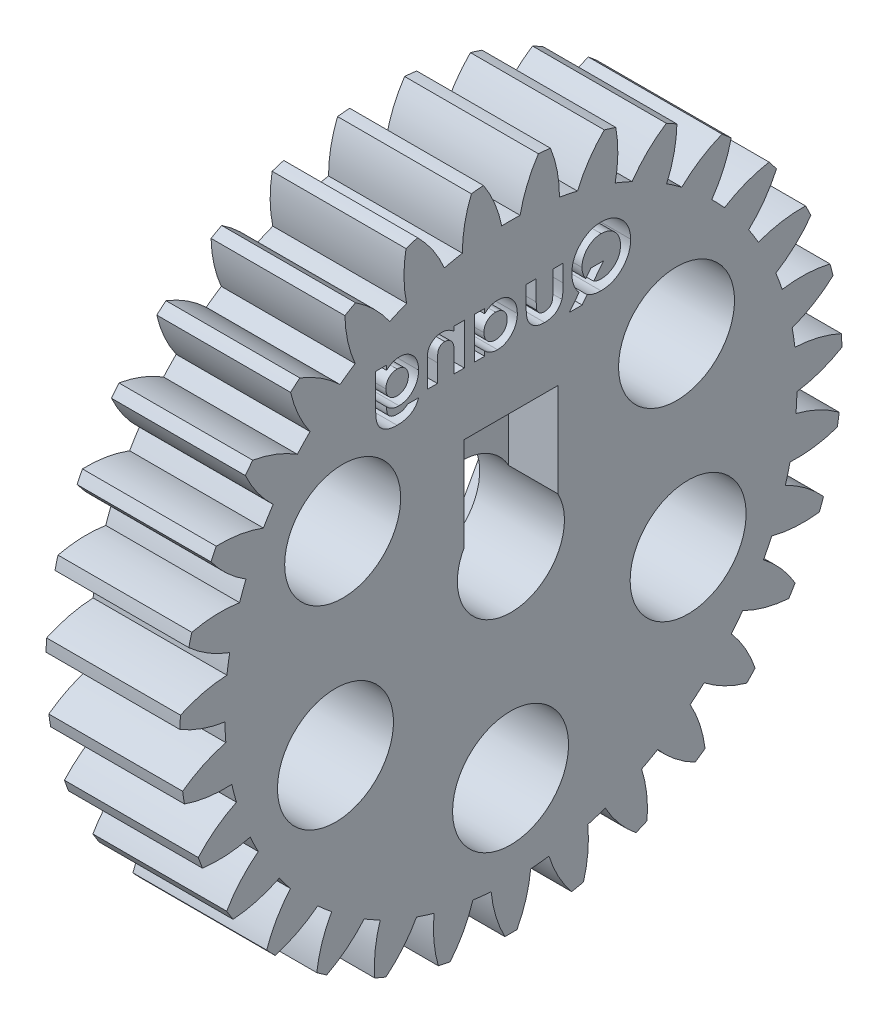
from build123d import *

# Parameters (mm, degrees)
BASPROSKE_W        = 15
BASPROSKE_H        = 37.125
TOOTHCUT_DEPTH     = 55.603399619
TEETHCUTS_COUNT    = 31
BORSKE_R           = 6
BORE_DEPTH         = 50.0000508
CUT_EXTRUDE1_DEPTH = 5.5
CUT_EXTRUDE5_DEPTH = 5.5
SKETCH10_R         = 6.5
CUT_EXTRUDE6_DEPTH = 55.590168897
CUT_EXTRUDE7_DEPTH = 55.590168897


with BuildPart() as part:
    # BasProSke → Base-Revolve (revolve)
    with BuildSketch(Plane(origin=(0, 0, 0), x_dir=(1, 0, 0), z_dir=(0, 1, 0)), mode=Mode.PRIVATE) as base_revolve_sk:
        with Locations((7.5, 18.5625)):
            Rectangle(BASPROSKE_W, BASPROSKE_H)
    revolve(base_revolve_sk.sketch.rotate(Axis((-10, 0, 0), (1, 0, 0)), 180), axis=Axis((-10, 0, 0), (1, 0, 0)))

    # TooCutSke → ToothCut (cut, through all)
    with BuildSketch(Plane(origin=(0, 0, 0), x_dir=(0, 0, -1), z_dir=(1, 0, 0))):
        with BuildLine():
            ThreePointArc((1.030914544, 32.044921555), (0, 32.0615), (-1.030914544, 32.044921555))
            ThreePointArc((-1.030914544, 32.044921555), (-1.820854389, 34.633687107), (-3.095833874, 37.021183568))
            ThreePointArc((-3.095833874, 37.021183568), (0, 37.1504), (3.095833874, 37.021183568))
            ThreePointArc((3.095833874, 37.021183568), (1.820854389, 34.633687107), (1.030914544, 32.044921555))
        make_face()
    toothcut = extrude(amount=TOOTHCUT_DEPTH, mode=Mode.SUBTRACT)

    # TeethCuts: ToothCut ×31 about axis
    teethcuts_axis = Axis((0, 0, 0), (1, 0, 0))
    for i in range(1, TEETHCUTS_COUNT):
        add(toothcut.rotate(teethcuts_axis, i * 360 / TEETHCUTS_COUNT), mode=Mode.SUBTRACT)

    # BorSke → Bore (cut, symmetric)
    with BuildSketch(Plane(origin=(0, 0, 0), x_dir=(0, 0, -1), z_dir=(1, 0, 0))):
        with Locations(Location((0, 0, 0), (0, 0, 180))):
            Circle(BORSKE_R)
    extrude(amount=BORE_DEPTH, both=True, mode=Mode.SUBTRACT)

    # Sketch2 → Cut-Extrude1 (cut)
    with BuildSketch(Plane(origin=(15, 0, 0), x_dir=(0, 0, -1), z_dir=(1, 0, 0))):
        with BuildLine():
            Line((-5.25, 2.90473751), (-5.25, 13.40473751))
            Line((-5.25, 13.40473751), (5.25, 13.40473751))
            Line((5.25, 13.40473751), (5.25, 2.90473751))
            ThreePointArc((5.25, 2.90473751), (0, -6), (-5.25, 2.90473751))
        make_face()
    extrude(amount=-CUT_EXTRUDE1_DEPTH, mode=Mode.SUBTRACT)

    # Sketch8 → Cut-Extrude5 (cut)
    with BuildSketch(Plane.ZY):
        Polygon((13.854005973, -0.294685119), (7.150361146, 11.832191891), (-6.703644827, 12.090103679), (-13.854005973, 0.221138455), (-7.150361146, -11.905738556), (6.703644827, -12.163650343), align=None)
    extrude(amount=-CUT_EXTRUDE5_DEPTH, mode=Mode.SUBTRACT)

    # Sketch10 → Cut-Extrude6 (cut, through all)
    with BuildSketch(Plane.ZY):
        with Locations((-19.863387595, -9.577864097)):
            Circle(SKETCH10_R)
        with Locations((0.040469936, -22.041338682)):
            Circle(SKETCH10_R)
        with Locations((19.66580652, -10.026222395)):
            Circle(SKETCH10_R)
        with Locations((18.858194519, 11.322709237)):
            Circle(SKETCH10_R)
        with Locations((-18.562453348, 11.784144122)):
            Circle(SKETCH10_R)
    extrude(amount=-CUT_EXTRUDE6_DEPTH, mode=Mode.SUBTRACT)

    # Sketch1 → Cut-Extrude7 (cut, through all)
    with BuildSketch(Plane.ZY):
        with BuildLine():
            Line((-7.641186471, 21.253862956), (-6.563772609, 19.86098435))
            Line((-6.563772609, 19.86098435), (-7.98209192, 19.86098435))
            Line((-7.98209192, 19.86098435), (-8.540515397, 20.58222834))
            add(Edge.make_bspline(
                [(-8.540515397, 20.58222834), (-8.599008563, 20.550378263), (-8.715718982, 20.486828344), (-8.898736314, 20.407582104), (-9.085141625, 20.338061517), (-9.277635984, 20.283585216), (-9.474371277, 20.240705753), (-9.676366873, 20.20796658), (-9.883478236, 20.190703942), (-10.023256563, 20.187991686), (-10.093670445, 20.186625375)],
                knots=[0, 0, 0, 0, 0.985706899, 1.966764212, 2.949968678, 3.929638882, 4.925906056, 5.930211904, 6.957336097, 8, 8, 8, 8], degree=3))
            add(Edge.make_bspline(
                [(-10.093670445, 20.186625375), (-10.210880259, 20.18925615), (-10.440772545, 20.194416084), (-10.777455868, 20.243961561), (-11.099762177, 20.318761769), (-11.406495093, 20.428048698), (-11.698687954, 20.566928028), (-11.974004928, 20.739035754), (-12.23564842, 20.93960012), (-12.477217009, 21.170589506), (-12.6982485, 21.420909481), (-12.891377178, 21.686855548), (-13.055549237, 21.964278382), (-13.189436194, 22.253613167), (-13.293546912, 22.555358711), (-13.366454823, 22.868690851), (-13.412677272, 23.194042611), (-13.418406665, 23.414894425), (-13.421314676, 23.526989959)],
                knots=[0, 0, 0, 0, 1.070144486, 2.098953612, 3.10240755, 4.088674545, 5.067611437, 6.052256776, 7.0494179, 8.074208254, 9.100739571, 10.09639475, 11.072322686, 12.041159829, 13.004031207, 13.983083054, 14.976293755, 16, 16, 16, 16], degree=3))
            add(Edge.make_bspline(
                [(-13.421314676, 23.526989959), (-13.420345258, 23.60210065), (-13.418418696, 23.75137096), (-13.395247606, 23.972587111), (-13.361816544, 24.189465169), (-13.312731245, 24.400839378), (-13.252205704, 24.608260467), (-13.175195253, 24.810079235), (-13.085947346, 25.008212108), (-12.983560241, 25.201013084), (-12.867262291, 25.385631499), (-12.743678018, 25.563534305), (-12.606210089, 25.729009408), (-12.459724098, 25.885783358), (-12.303738891, 26.033753471), (-12.135797934, 26.169869763), (-11.959092572, 26.297510154), (-11.772349608, 26.413998694), (-11.578810958, 26.519293027), (-11.380257916, 26.610800943), (-11.178201723, 26.689085055), (-10.972566994, 26.752856596), (-10.762728229, 26.800646937), (-10.550531843, 26.837034088), (-10.334053702, 26.857274846), (-10.188687803, 26.860591752), (-10.115295045, 26.862266401)],
                knots=[0, 0, 0, 0, 1.035855852, 2.058595393, 3.065553363, 4.06176554, 5.050183643, 6.044349766, 7.039272903, 8.046842428, 9.053256483, 10.04817962, 11.033146707, 12.018200652, 13.007259073, 13.996749908, 14.99846043, 16.012935138, 17.03119782, 18.036301871, 19.027088812, 20.018894167, 21.003704893, 21.994284571, 22.987348552, 24, 24, 24, 24], degree=3))
            add(Edge.make_bspline(
                [(-10.115295045, 26.862266401), (-10.004460187, 26.859448074), (-9.786059909, 26.853894556), (-9.464794519, 26.806406983), (-9.154984646, 26.730760422), (-8.857907783, 26.621465962), (-8.571748198, 26.483660245), (-8.299357848, 26.31314767), (-8.037854341, 26.113444463), (-7.792887064, 25.884454725), (-7.56650124, 25.635945717), (-7.36914622, 25.369323247), (-7.202073321, 25.08967801), (-7.062741889, 24.796898515), (-6.957771037, 24.489273684), (-6.882834444, 24.168845952), (-6.835401763, 23.835389886), (-6.8298867, 23.608136671), (-6.827083907, 23.492645007)],
                knots=[0, 0, 0, 0, 1.015551519, 2.00114601, 2.970254478, 3.93428303, 4.897362978, 5.876714212, 6.874912676, 7.909046156, 8.946527051, 9.952474942, 10.9443724, 11.928494229, 12.919233427, 13.917651329, 14.941735923, 16, 16, 16, 16], degree=3))
            add(Edge.make_bspline(
                [(-6.827083907, 23.492645007), (-6.829414032, 23.386095041), (-6.83399693, 23.176532258), (-6.873699855, 22.86759324), (-6.93636794, 22.569817408), (-7.026374597, 22.282993142), (-7.140437741, 22.007433074), (-7.282560761, 21.74395756), (-7.446446536, 21.489438608), (-7.57594954, 21.332779653), (-7.641186471, 21.253862956)],
                knots=[0, 0, 0, 0, 1.049646143, 2.064447078, 3.064298101, 4.044929938, 5.022708814, 5.998521441, 6.991758374, 8, 8, 8, 8], degree=3))
        make_face()
        with BuildLine():
            add(Edge.make_bspline(
                [(-8.389143202, 22.223153821), (-8.355216616, 22.271794044), (-8.288145085, 22.367953859), (-8.203277946, 22.520476402), (-8.130376114, 22.675970785), (-8.070089153, 22.835252945), (-8.024228931, 22.999235703), (-7.99163252, 23.166848526), (-7.97004659, 23.338168176), (-7.967906139, 23.453570571), (-7.966827496, 23.511725536)],
                knots=[0, 0, 0, 0, 1.031533623, 2.039301536, 3.033003023, 4.018477747, 4.999688364, 5.992485227, 6.988348989, 8, 8, 8, 8], degree=3))
            add(Edge.make_bspline(
                [(-7.966827496, 23.511725536), (-7.968835024, 23.587291547), (-7.972786534, 23.736031717), (-8.00246554, 23.954681956), (-8.052185579, 24.16422786), (-8.121512714, 24.365182316), (-8.208819263, 24.558061171), (-8.318494734, 24.741258373), (-8.447349008, 24.915725421), (-8.594138221, 25.079782123), (-8.753953138, 25.229930322), (-8.923920183, 25.362166764), (-9.102873443, 25.473726777), (-9.290917602, 25.563804203), (-9.486012833, 25.636355177), (-9.690252803, 25.685051764), (-9.901857336, 25.716980549), (-10.046062508, 25.720659301), (-10.11911115, 25.722522811)],
                knots=[0, 0, 0, 0, 1.056263418, 2.079093448, 3.078410197, 4.062632158, 5.04680056, 6.032966551, 7.041959893, 8.074807684, 9.106532056, 10.103754224, 11.080880922, 12.048629763, 13.014470275, 13.984975, 14.979267944, 16, 16, 16, 16], degree=3))
            add(Edge.make_bspline(
                [(-10.11911115, 25.722522811), (-10.194263213, 25.720556592), (-10.342178552, 25.716686652), (-10.559331029, 25.686435276), (-10.767626119, 25.638984866), (-10.965968935, 25.569315654), (-11.154960023, 25.481530925), (-11.334590713, 25.373817356), (-11.503960766, 25.245571809), (-11.663472867, 25.100550705), (-11.807597629, 24.939629641), (-11.934868315, 24.767068306), (-12.041390578, 24.583282804), (-12.130599072, 24.389946767), (-12.197754431, 24.184895177), (-12.24558688, 23.969731807), (-12.275815279, 23.744086586), (-12.2796256, 23.590264507), (-12.281571086, 23.511725536)],
                knots=[0, 0, 0, 0, 1.042613217, 2.052085894, 3.036973397, 4.002832266, 4.963730975, 5.924467509, 6.903642813, 7.907474205, 8.911719447, 9.896835452, 10.877830278, 11.85475743, 12.846581833, 13.865885605, 14.910357018, 16, 16, 16, 16], degree=3))
            add(Edge.make_bspline(
                [(-12.281571086, 23.511725536), (-12.278992235, 23.42468629), (-12.273938115, 23.25410379), (-12.238360872, 23.005269419), (-12.177534183, 22.770244456), (-12.08955614, 22.550297755), (-11.98083894, 22.342332537), (-11.84387385, 22.150778083), (-11.684608625, 21.97184692), (-11.561667409, 21.867693093), (-11.499269404, 21.814830504)],
                knots=[0, 0, 0, 0, 1.078047314, 2.112794111, 3.106520711, 4.077995885, 5.041371964, 6.006121678, 6.988020189, 8, 8, 8, 8], degree=3))
            add(Edge.make_bspline(
                [(-11.499269404, 21.814830504), (-11.448215961, 21.775698756), (-11.346972677, 21.698097198), (-11.184789839, 21.599869275), (-11.018561967, 21.51453824), (-10.846717288, 21.446317006), (-10.669849446, 21.392060924), (-10.487996051, 21.354477525), (-10.300801881, 21.330554081), (-10.174306058, 21.327776465), (-10.110206904, 21.326368965)],
                knots=[0, 0, 0, 0, 1.027457745, 2.037535419, 3.025615023, 4.011018129, 4.9886297, 5.978868484, 6.975833209, 8, 8, 8, 8], degree=3))
            add(Edge.make_bspline(
                [(-10.110206904, 21.326368965), (-10.036663248, 21.328710676), (-9.890692627, 21.333358542), (-9.675836839, 21.373845591), (-9.46649759, 21.434394899), (-9.335258453, 21.496287577), (-9.269391599, 21.527350536)],
                knots=[0, 0, 0, 0, 1.010952568, 2.006554787, 2.999521277, 4, 4, 4, 4], degree=3))
            Line((-9.269391599, 21.527350536), (-10.372246166, 22.954574093))
            Line((-10.372246166, 22.954574093), (-8.953926855, 22.954574093))
            Line((-8.953926855, 22.954574093), (-8.389143202, 22.223153821))
        make_face(mode=Mode.SUBTRACT)
        with BuildLine():
            Line((-5.85016083, 24.989830504), (-4.71041724, 24.989830504))
            Line((-4.71041724, 24.989830504), (-4.71041724, 22.76249677))
            add(Edge.make_bspline(
                [(-4.71041724, 22.76249677), (-4.71031603, 22.71033799), (-4.710121784, 22.610232554), (-4.704716541, 22.46646155), (-4.697131918, 22.33498955), (-4.68766682, 22.215661525), (-4.673539556, 22.108764498), (-4.657230225, 22.01450254), (-4.638740705, 21.93219648), (-4.608674411, 21.840455403), (-4.561635151, 21.740062438), (-4.490597542, 21.633483517), (-4.404550277, 21.541323914), (-4.304655914, 21.462765759), (-4.189894285, 21.400860208), (-4.061846505, 21.358907761), (-3.922123676, 21.330711354), (-3.824806935, 21.327854576), (-3.774199291, 21.326368965)],
                knots=[0, 0, 0, 0, 1.267339619, 2.432334223, 3.495366327, 4.467371443, 5.340232306, 6.114347373, 6.791623365, 7.387877112, 8.457231658, 9.474542289, 10.487879852, 11.508108106, 12.54995813, 13.638205937, 14.771795776, 16, 16, 16, 16], degree=3))
            add(Edge.make_bspline(
                [(-3.774199291, 21.326368965), (-3.723636557, 21.32806458), (-3.626068139, 21.331336524), (-3.48541568, 21.356852016), (-3.357066298, 21.40057366), (-3.239701762, 21.459876911), (-3.136783159, 21.539244211), (-3.047176141, 21.63381598), (-2.971729134, 21.745117777), (-2.935473368, 21.828145728), (-2.916847529, 21.870800055)],
                knots=[0, 0, 0, 0, 1.116871431, 2.155171802, 3.144773418, 4.104381479, 5.046960687, 6.001340237, 6.973219418, 8, 8, 8, 8], degree=3))
            add(Edge.make_bspline(
                [(-2.916847529, 21.870800055), (-2.910012471, 21.88974749), (-2.89492487, 21.931571767), (-2.881496607, 22.0037244), (-2.867043797, 22.088816748), (-2.855611111, 22.188582922), (-2.849142093, 22.302405061), (-2.842211204, 22.430426618), (-2.838679098, 22.572520094), (-2.83822105, 22.67218091), (-2.837981343, 22.724335712)],
                knots=[0, 0, 0, 0, 0.56094539, 1.238222264, 2.041156151, 2.969685991, 4.036367568, 5.220421584, 6.545382566, 8, 8, 8, 8], degree=3))
            Line((-2.837981343, 22.724335712), (-2.837981343, 24.989830504))
            Line((-2.837981343, 24.989830504), (-1.698237753, 24.989830504))
            Line((-1.698237753, 24.989830504), (-1.698237753, 23.039800456))
            add(Edge.make_bspline(
                [(-1.698237753, 23.039800456), (-1.698435098, 22.94311383), (-1.698813469, 22.757736306), (-1.709657351, 22.491818272), (-1.724623137, 22.250045703), (-1.743896189, 22.031752923), (-1.771666277, 21.83684934), (-1.805755539, 21.665792008), (-1.843469146, 21.517450556), (-1.87805393, 21.429557221), (-1.894131182, 21.388698693)],
                knots=[0, 0, 0, 0, 1.388070971, 2.661352173, 3.82033814, 4.865898334, 5.806910977, 6.645039373, 7.370126333, 8, 8, 8, 8], degree=3))
            add(Edge.make_bspline(
                [(-1.894131182, 21.388698693), (-1.91473808, 21.344722292), (-1.955414324, 21.257916656), (-2.02599517, 21.134498266), (-2.102085275, 21.01756912), (-2.187305036, 20.909881613), (-2.279914853, 20.810341277), (-2.377296938, 20.716685317), (-2.483836874, 20.632727545), (-2.596771687, 20.556307491), (-2.717677224, 20.488470053), (-2.845725373, 20.428354593), (-2.982299896, 20.379430917), (-3.126216531, 20.337961201), (-3.278138638, 20.307035101), (-3.43776019, 20.28361094), (-3.605256251, 20.271505244), (-3.719485463, 20.269211119), (-3.778015397, 20.268035632)],
                knots=[0, 0, 0, 0, 0.997311338, 1.968606903, 2.91805772, 3.860812155, 4.785445165, 5.709667791, 6.633356648, 7.568312411, 8.508286151, 9.478643871, 10.470653671, 11.485274776, 12.552984541, 13.653035246, 14.797438149, 16, 16, 16, 16], degree=3))
            add(Edge.make_bspline(
                [(-3.778015397, 20.268035632), (-3.841244173, 20.268789152), (-3.964961447, 20.270263535), (-4.145710655, 20.288318955), (-4.31796708, 20.31168032), (-4.479807491, 20.351398923), (-4.633492063, 20.397414911), (-4.777256411, 20.456143552), (-4.911687991, 20.525191794), (-5.037051317, 20.60415028), (-5.152374117, 20.693742581), (-5.26022072, 20.790095982), (-5.357109376, 20.897044079), (-5.446203105, 21.011284273), (-5.526507571, 21.133867972), (-5.598062631, 21.264359306), (-5.660928898, 21.403351815), (-5.694471169, 21.500765718), (-5.711508987, 21.55024717)],
                knots=[0, 0, 0, 0, 1.211240017, 2.369985978, 3.478996442, 4.539426614, 5.559871561, 6.551301256, 7.510778031, 8.453136967, 9.386094087, 10.30661716, 11.221130616, 12.147659962, 13.080758632, 14.026335491, 14.997475882, 16, 16, 16, 16], degree=3))
            add(Edge.make_bspline(
                [(-5.711508987, 21.55024717), (-5.723132742, 21.58867636), (-5.748173019, 21.671461794), (-5.775208847, 21.809041523), (-5.796833085, 21.967609864), (-5.81786846, 22.14732279), (-5.832543122, 22.348481592), (-5.842134656, 22.570766802), (-5.848615359, 22.814613099), (-5.849630496, 22.984250427), (-5.85016083, 23.072873372)],
                knots=[0, 0, 0, 0, 0.627914866, 1.352675004, 2.190563461, 3.132055958, 4.183353232, 5.345633452, 6.613289997, 8, 8, 8, 8], degree=3))
            Line((-5.85016083, 23.072873372), (-5.85016083, 24.989830504))
        make_face()
        with BuildLine():
            Line((2.942146863, 24.989830504), (4.081890452, 24.989830504))
            Line((4.081890452, 24.989830504), (4.081890452, 20.349445888))
            Line((4.081890452, 20.349445888), (2.942146863, 20.349445888))
            Line((2.942146863, 20.349445888), (2.942146863, 20.85571592))
            add(Edge.make_bspline(
                [(2.942146863, 20.85571592), (2.885672988, 20.806436136), (2.776068349, 20.710793806), (2.603366904, 20.586695452), (2.430160806, 20.484330348), (2.255617794, 20.402802125), (2.077055215, 20.342601924), (1.893187491, 20.299015572), (1.701366731, 20.273311634), (1.570969621, 20.269812618), (1.504747023, 20.268035632)],
                knots=[0, 0, 0, 0, 1.129196829, 2.191548051, 3.199897424, 4.157751732, 5.089409408, 6.034969131, 7.002052659, 8, 8, 8, 8], degree=3))
            add(Edge.make_bspline(
                [(1.504747023, 20.268035632), (1.430409213, 20.269708), (1.283513487, 20.273012694), (1.067960317, 20.307799935), (0.859822302, 20.36104956), (0.659268392, 20.436404435), (0.466663477, 20.53404958), (0.280533544, 20.651437297), (0.104069428, 20.792688597), (-0.064197874, 20.951691896), (-0.218262406, 21.126596656), (-0.352947074, 21.314975224), (-0.46647624, 21.514155864), (-0.559484611, 21.723478202), (-0.632647705, 21.942788606), (-0.684802522, 22.172782664), (-0.715573924, 22.413542516), (-0.719382557, 22.577538698), (-0.721314676, 22.660733949)],
                knots=[0, 0, 0, 0, 0.980476535, 1.937477201, 2.874147792, 3.812856188, 4.758993464, 5.720109578, 6.712210464, 7.737600662, 8.772720504, 9.783789959, 10.789002326, 11.793715968, 12.802552247, 13.835794126, 14.902098527, 16, 16, 16, 16], degree=3))
            add(Edge.make_bspline(
                [(-0.721314676, 22.660733949), (-0.71928691, 22.746882741), (-0.715309221, 22.915873194), (-0.686212662, 23.16385865), (-0.635020298, 23.399555391), (-0.565215829, 23.623289891), (-0.475424501, 23.835100804), (-0.366064663, 24.035335142), (-0.235648576, 24.223469527), (-0.085367156, 24.396301777), (0.076899866, 24.554710883), (0.250496894, 24.692618571), (0.43270925, 24.80977757), (0.623730565, 24.905424778), (0.823533562, 24.9793361), (1.031329421, 25.033371312), (1.248040608, 25.065794337), (1.395666026, 25.069410209), (1.470402071, 25.07124076)],
                knots=[0, 0, 0, 0, 1.136281865, 2.228943489, 3.287578264, 4.313574083, 5.316051562, 6.317280042, 7.318008486, 8.329309503, 9.333984563, 10.305318864, 11.248632312, 12.186624717, 13.117503092, 14.05354244, 15.014596925, 16, 16, 16, 16], degree=3))
            add(Edge.make_bspline(
                [(1.470402071, 25.07124076), (1.539631865, 25.069802497), (1.676612673, 25.066956692), (1.877954724, 25.036056696), (2.073227475, 24.989322647), (2.261365702, 24.922735039), (2.443912577, 24.838654637), (2.61772818, 24.733295627), (2.786614883, 24.6110862), (2.889662326, 24.515638048), (2.942146863, 24.467024013)],
                knots=[0, 0, 0, 0, 1.017011718, 2.012299608, 2.98747302, 3.965332399, 4.941441765, 5.936729654, 6.94912688, 8, 8, 8, 8], degree=3))
            Line((2.942146863, 24.467024013), (2.942146863, 24.989830504))
        make_face()
        with BuildLine():
            add(Edge.make_bspline(
                [(1.709544699, 24.012907427), (1.664129277, 24.011513925), (1.575118014, 24.008782752), (1.444214772, 23.992354557), (1.319110541, 23.963407346), (1.200697556, 23.920644057), (1.087211028, 23.868552141), (0.980374268, 23.803307874), (0.879305519, 23.726190536), (0.784599178, 23.639067138), (0.698260394, 23.543302594), (0.623831323, 23.438802728), (0.560578638, 23.328383217), (0.507083305, 23.211712069), (0.468792783, 23.087408701), (0.438466706, 22.957091325), (0.422729435, 22.819695312), (0.419876764, 22.726064181), (0.418428914, 22.678542443)],
                knots=[0, 0, 0, 0, 1.04836806, 2.054732945, 3.03993516, 4.00574415, 4.955904794, 5.917688631, 6.888591924, 7.88601754, 8.884115178, 9.859153345, 10.841239365, 11.818093293, 12.814750328, 13.83810466, 14.90274714, 16, 16, 16, 16], degree=3))
            add(Edge.make_bspline(
                [(0.418428914, 22.678542443), (0.419854648, 22.630589654), (0.422664041, 22.536099241), (0.438721163, 22.397544243), (0.467955982, 22.265323236), (0.510608482, 22.140505135), (0.562697077, 22.021405732), (0.626100612, 21.908574681), (0.703980749, 21.804006977), (0.790395218, 21.705228197), (0.887044445, 21.617022579), (0.988685082, 21.53870409), (1.096705459, 21.473175059), (1.209933631, 21.420214083), (1.327988468, 21.377055338), (1.45235002, 21.348471934), (1.581800007, 21.330199105), (1.670049482, 21.327654494), (1.71463284, 21.326368965)],
                knots=[0, 0, 0, 0, 1.099136573, 2.165835871, 3.191374663, 4.196217796, 5.183857741, 6.167377911, 7.154730987, 8.166690795, 9.170734848, 10.148332609, 11.103258353, 12.059567475, 13.009337315, 13.978056681, 14.978520572, 16, 16, 16, 16], degree=3))
            add(Edge.make_bspline(
                [(1.71463284, 21.326368965), (1.760894178, 21.327770279), (1.851591548, 21.330517617), (1.984630411, 21.346795887), (2.11141524, 21.375849236), (2.231418542, 21.418857353), (2.346473254, 21.470575353), (2.455541111, 21.534544697), (2.557438561, 21.611485072), (2.652681668, 21.699396068), (2.739953616, 21.795942587), (2.815411982, 21.901812803), (2.881138979, 22.013620695), (2.932830239, 22.134009811), (2.973880348, 22.260873902), (3.003332854, 22.395000315), (3.01935331, 22.536533652), (3.022138132, 22.63313567), (3.023557119, 22.682358548)],
                knots=[0, 0, 0, 0, 1.050008698, 2.058587853, 3.036635738, 3.995319155, 4.947022481, 5.895997462, 6.858296291, 7.838991643, 8.833936038, 9.806048392, 10.784806122, 11.771666913, 12.772873988, 13.80724452, 14.882696879, 16, 16, 16, 16], degree=3))
            add(Edge.make_bspline(
                [(3.023557119, 22.682358548), (3.022155765, 22.730734817), (3.019418513, 22.825227721), (3.003263762, 22.963805909), (2.97360216, 23.095298691), (2.93339693, 23.219947768), (2.880786067, 23.33746813), (2.815009339, 23.446556757), (2.740378708, 23.550993161), (2.652140533, 23.644931424), (2.557413379, 23.732205877), (2.454017362, 23.806819518), (2.345210018, 23.871123625), (2.230322831, 23.923919777), (2.108292, 23.962621357), (1.981290504, 23.992586575), (1.847336857, 24.008772892), (1.756224956, 24.011506758), (1.709544699, 24.012907427)],
                knots=[0, 0, 0, 0, 1.106611376, 2.161533483, 3.185006901, 4.184773755, 5.152708835, 6.122342771, 7.094156588, 8.082475533, 9.064254463, 10.03606828, 10.992420271, 11.951521816, 12.920622147, 13.915721683, 14.932141191, 16, 16, 16, 16], degree=3))
        make_face(mode=Mode.SUBTRACT)
        with BuildLine():
            Line((5.221634042, 24.989830504), (6.361377632, 24.989830504))
            Line((6.361377632, 24.989830504), (6.361377632, 24.498824895))
            add(Edge.make_bspline(
                [(6.361377632, 24.498824895), (6.426399439, 24.549400195), (6.550668751, 24.646059426), (6.739579563, 24.769300438), (6.917887979, 24.870168257), (7.089568688, 24.946893482), (7.257851864, 25.002093983), (7.425462975, 25.041752249), (7.59489809, 25.067146528), (7.708799616, 25.069876748), (7.765704555, 25.07124076)],
                knots=[0, 0, 0, 0, 1.276643801, 2.439914479, 3.493451431, 4.44993799, 5.350072675, 6.235028322, 7.118224225, 8, 8, 8, 8], degree=3))
            add(Edge.make_bspline(
                [(7.765704555, 25.07124076), (7.823426958, 25.069681977), (7.936740883, 25.066621955), (8.103589393, 25.045219578), (8.262996941, 25.006239071), (8.416755934, 24.9544835), (8.563301367, 24.886169114), (8.704428512, 24.805056865), (8.837106008, 24.706256658), (8.918814683, 24.631015164), (8.960145661, 24.592955504)],
                knots=[0, 0, 0, 0, 1.048836932, 2.058954983, 3.049370783, 4.026390553, 5.001981509, 5.982488534, 6.97947532, 8, 8, 8, 8], degree=3))
            add(Edge.make_bspline(
                [(8.960145661, 24.592955504), (8.993294626, 24.557685328), (9.059835167, 24.48688684), (9.143568077, 24.365732494), (9.215420333, 24.233652082), (9.274293272, 24.089122012), (9.317798003, 23.931348187), (9.351266785, 23.762236287), (9.370046703, 23.580839411), (9.372365172, 23.456221469), (9.373557119, 23.392154222)],
                knots=[0, 0, 0, 0, 0.889584746, 1.785680191, 2.700364693, 3.65222533, 4.649950538, 5.707241244, 6.821271309, 8, 8, 8, 8], degree=3))
            Line((9.373557119, 23.392154222), (9.373557119, 20.349445888))
            Line((9.373557119, 20.349445888), (8.233813529, 20.349445888))
            Line((8.233813529, 20.349445888), (8.233813529, 22.364349734))
            add(Edge.make_bspline(
                [(8.233813529, 22.364349734), (8.233572499, 22.430072388), (8.233110608, 22.556017654), (8.229564312, 22.736264258), (8.222639875, 22.899050349), (8.216328432, 23.044672313), (8.20393656, 23.172613095), (8.192761369, 23.283682656), (8.175614122, 23.376873367), (8.153302773, 23.477113959), (8.114341661, 23.584439844), (8.053856434, 23.697525394), (7.977122442, 23.79359409), (7.887273808, 23.873319421), (7.784409761, 23.936389471), (7.669773265, 23.980763179), (7.543978908, 24.008417964), (7.456326878, 24.011372864), (7.410806718, 24.012907427)],
                knots=[0, 0, 0, 0, 1.49886392, 2.872294502, 4.110984203, 5.214877267, 6.195405875, 7.042225351, 7.75923308, 8.355011229, 9.382752534, 10.352059385, 11.267231453, 12.171456522, 13.078624015, 14.003401117, 14.963110155, 16, 16, 16, 16], degree=3))
            add(Edge.make_bspline(
                [(7.410806718, 24.012907427), (7.351605836, 24.009905334), (7.235797402, 24.004032657), (7.068303669, 23.959747317), (6.914463467, 23.88443099), (6.775533795, 23.780208337), (6.652837843, 23.651532558), (6.551782202, 23.49807193), (6.468895816, 23.323530217), (6.433253438, 23.196086416), (6.414803113, 23.130114959)],
                knots=[0, 0, 0, 0, 0.984188326, 1.925263693, 2.85911992, 3.81709677, 4.80007086, 5.801799564, 6.862098548, 8, 8, 8, 8], degree=3))
            add(Edge.make_bspline(
                [(6.414803113, 23.130114959), (6.410217474, 23.10939618), (6.399990577, 23.063189139), (6.391580248, 22.985127394), (6.37988087, 22.892514691), (6.375497401, 22.783675001), (6.36787503, 22.659123418), (6.365055913, 22.518695162), (6.362231752, 22.362665589), (6.361671771, 22.253684861), (6.361377632, 22.196441081)],
                knots=[0, 0, 0, 0, 0.543362196, 1.211806945, 2.009705693, 2.934833164, 4.000995085, 5.207458376, 6.533175157, 8, 8, 8, 8], degree=3))
            Line((6.361377632, 22.196441081), (6.361377632, 20.349445888))
            Line((6.361377632, 20.349445888), (5.221634042, 20.349445888))
            Line((5.221634042, 20.349445888), (5.221634042, 24.989830504))
        make_face()
        with BuildLine():
            Line((13.932531478, 24.989830504), (15.153685324, 24.989830504))
            Line((15.153685324, 24.989830504), (15.153685324, 21.031256786))
            add(Edge.make_bspline(
                [(15.153685324, 21.031256786), (15.152217815, 20.936659481), (15.149383998, 20.753988371), (15.127766832, 20.48925075), (15.091717421, 20.243824413), (15.039843591, 20.01736178), (14.972846046, 19.810695208), (14.890905506, 19.623137633), (14.795687993, 19.453683236), (14.717398003, 19.354666964), (14.679216173, 19.306376978)],
                knots=[0, 0, 0, 0, 1.243822755, 2.401870584, 3.490053692, 4.503076575, 5.453444971, 6.342269266, 7.191528908, 8, 8, 8, 8], degree=3))
            add(Edge.make_bspline(
                [(14.679216173, 19.306376978), (14.624386538, 19.24623512), (14.515004857, 19.12625589), (14.322158823, 18.974846347), (14.110888888, 18.84543933), (13.879039008, 18.739384077), (13.626885341, 18.658603808), (13.355075645, 18.600427618), (13.063437601, 18.564192746), (12.862011007, 18.560380434), (12.758442936, 18.558420247)],
                knots=[0, 0, 0, 0, 0.916003385, 1.827369254, 2.751972866, 3.703651841, 4.69362366, 5.730423306, 6.83304546, 8, 8, 8, 8], degree=3))
            add(Edge.make_bspline(
                [(12.758442936, 18.558420247), (12.648965494, 18.56011509), (12.438412183, 18.563374709), (12.135851415, 18.595261256), (11.860247711, 18.647728369), (11.610306839, 18.721594628), (11.383700231, 18.816903465), (11.176154659, 18.931184259), (10.988068709, 19.067816355), (10.816599373, 19.221413228), (10.665723349, 19.395347943), (10.536890027, 19.588028009), (10.427130734, 19.797681153), (10.372935835, 19.947607133), (10.345392055, 20.023804863)],
                knots=[0, 0, 0, 0, 1.29412125, 2.488928388, 3.592140377, 4.607309753, 5.564519828, 6.493640275, 7.402258018, 8.307438948, 9.210158992, 10.116782752, 11.042881838, 12, 12, 12, 12], degree=3))
            Line((10.345392055, 20.023804863), (11.61233917, 20.023804863))
            add(Edge.make_bspline(
                [(11.61233917, 20.023804863), (11.641616964, 19.991572803), (11.700544615, 19.926699076), (11.80477157, 19.844378711), (11.920070207, 19.773916492), (12.047370751, 19.716219291), (12.187203986, 19.672345743), (12.338618048, 19.639013628), (12.502291152, 19.620229236), (12.615080143, 19.617935746), (12.673216574, 19.616753581)],
                knots=[0, 0, 0, 0, 0.888971165, 1.789239437, 2.70354581, 3.646217955, 4.638595249, 5.694475788, 6.811630907, 8, 8, 8, 8], degree=3))
            add(Edge.make_bspline(
                [(12.673216574, 19.616753581), (12.746685736, 19.61812631), (12.887005397, 19.620748103), (13.085526763, 19.649414559), (13.262810236, 19.692240568), (13.416296641, 19.756692666), (13.548716839, 19.834108504), (13.659187529, 19.924037065), (13.75040419, 20.023090273), (13.810069431, 20.11627514), (13.845524737, 20.200808923), (13.869667686, 20.273802628), (13.888002101, 20.357941121), (13.904691256, 20.451649635), (13.91716667, 20.556135447), (13.925431792, 20.671177204), (13.932598893, 20.796268056), (13.932554446, 20.8832649), (13.932531478, 20.92822193)],
                knots=[0, 0, 0, 0, 1.656375485, 3.163532, 4.516250129, 5.759907703, 6.905105653, 7.965920022, 8.961443813, 9.932912751, 10.442911961, 11.026787936, 11.664959534, 12.383728702, 13.174001396, 14.037595414, 14.985895623, 16, 16, 16, 16], degree=3))
            add(Edge.make_bspline(
                [(13.932531478, 20.92822193), (13.882599658, 20.879249512), (13.785163039, 20.783685063), (13.62698991, 20.661765401), (13.465071703, 20.561062761), (13.2984779, 20.481008572), (13.123895329, 20.422370291), (12.940298602, 20.38025595), (12.745596783, 20.354595011), (12.611813335, 20.351186933), (12.543468978, 20.349445888)],
                knots=[0, 0, 0, 0, 1.082007397, 2.111422008, 3.08419067, 4.02964304, 4.965866572, 5.929243163, 6.942137121, 8, 8, 8, 8], degree=3))
            add(Edge.make_bspline(
                [(12.543468978, 20.349445888), (12.467872165, 20.351192318), (12.319373217, 20.354622925), (12.101258822, 20.38796172), (11.891997456, 20.439833632), (11.691025641, 20.512044185), (11.500394072, 20.607914258), (11.317389992, 20.721972902), (11.145405001, 20.860209248), (10.982066361, 21.01490649), (10.834437141, 21.186859244), (10.704532557, 21.37153627), (10.595019735, 21.567663669), (10.505960667, 21.775059119), (10.435003356, 21.992851984), (10.386169621, 22.222221341), (10.356328414, 22.462779912), (10.352455519, 22.626725063), (10.350480196, 22.710343324)],
                knots=[0, 0, 0, 0, 1.007560175, 1.979205489, 2.935124557, 3.879618859, 4.820364716, 5.775815361, 6.749909327, 7.75781854, 8.772289371, 9.766897274, 10.764314289, 11.762244114, 12.772609037, 13.814079916, 14.885097635, 16, 16, 16, 16], degree=3))
            add(Edge.make_bspline(
                [(10.350480196, 22.710343324), (10.352205445, 22.799491717), (10.35557723, 22.973721142), (10.388630342, 23.228205465), (10.440062584, 23.469895299), (10.51348346, 23.698285082), (10.609942015, 23.912398458), (10.726508321, 24.112914829), (10.862082775, 24.302127177), (10.969401281, 24.414374938), (11.023386846, 24.470840119)],
                knots=[0, 0, 0, 0, 1.104124469, 2.157873671, 3.173961494, 4.162551312, 5.124378318, 6.07778831, 7.033049473, 8, 8, 8, 8], degree=3))
            add(Edge.make_bspline(
                [(11.023386846, 24.470840119), (11.07461837, 24.518986658), (11.175572645, 24.613861819), (11.34083448, 24.735602397), (11.511991435, 24.840019442), (11.691391116, 24.924011182), (11.877764091, 24.990897606), (12.072213705, 25.037689968), (12.273773103, 25.06654106), (12.410656451, 25.069662501), (12.479867215, 25.07124076)],
                knots=[0, 0, 0, 0, 1.042068658, 2.053448347, 3.038272799, 4.011764631, 4.986555969, 5.970496305, 6.973845226, 8, 8, 8, 8], degree=3))
            add(Edge.make_bspline(
                [(12.479867215, 25.07124076), (12.544813684, 25.069417086), (12.673509226, 25.06580336), (12.864180106, 25.040306995), (13.048811636, 24.995263966), (13.229425401, 24.933339271), (13.40793576, 24.85312288), (13.584188454, 24.747983847), (13.761756951, 24.622267278), (13.874430366, 24.52403737), (13.932531478, 24.473384189)],
                knots=[0, 0, 0, 0, 0.968122651, 1.918396369, 2.861262201, 3.796768263, 4.761417965, 5.77287463, 6.85156174, 8, 8, 8, 8], degree=3))
            Line((13.932531478, 24.473384189), (13.932531478, 24.989830504))
        make_face()
        with BuildLine():
            add(Edge.make_bspline(
                [(12.75208276, 24.012907427), (12.707524144, 24.011471597), (12.619799715, 24.008644818), (12.490872496, 23.99271847), (12.36851997, 23.962655956), (12.251250947, 23.923620835), (12.140491214, 23.871110866), (12.036026657, 23.807044497), (11.936619037, 23.732681122), (11.84543156, 23.64661748), (11.760907022, 23.553623747), (11.689937271, 23.451278841), (11.626690571, 23.345410449), (11.577506879, 23.231758478), (11.53683628, 23.113407204), (11.511980089, 22.987948236), (11.492119224, 22.857674726), (11.490863804, 22.768516784), (11.490223786, 22.723063677)],
                knots=[0, 0, 0, 0, 1.059154978, 2.085203149, 3.079850876, 4.048488546, 5.017545358, 5.985239295, 6.956545898, 7.961752598, 8.960830395, 9.936516972, 10.916356752, 11.886198968, 12.873933111, 13.883774911, 14.921139228, 16, 16, 16, 16], degree=3))
            add(Edge.make_bspline(
                [(11.490223786, 22.723063677), (11.49091658, 22.67592817), (11.492276274, 22.583418931), (11.511313242, 22.448650249), (11.53850727, 22.31966851), (11.579586088, 22.198048171), (11.631012975, 22.082191207), (11.692788605, 21.97215455), (11.769047166, 21.870569125), (11.853729697, 21.775199336), (11.947411458, 21.688974135), (12.048251584, 21.613976738), (12.154173966, 21.549208767), (12.267468296, 21.498710317), (12.385683238, 21.45778906), (12.510004464, 21.428072049), (12.64014628, 21.412016116), (12.728721708, 21.40920628), (12.773707359, 21.407779222)],
                knots=[0, 0, 0, 0, 1.097915424, 2.154794285, 3.166904039, 4.167166757, 5.140698173, 6.119085138, 7.101657521, 8.095747232, 9.089148684, 10.06378348, 11.021581144, 11.977080764, 12.949256321, 13.934658686, 14.951055324, 16, 16, 16, 16], degree=3))
            add(Edge.make_bspline(
                [(12.773707359, 21.407779222), (12.817877862, 21.40847178), (12.904482256, 21.409829668), (13.03081358, 21.428878177), (13.151512764, 21.456420711), (13.266362432, 21.495806601), (13.374725194, 21.547213736), (13.478055155, 21.608560356), (13.574160481, 21.682796747), (13.664863827, 21.766726094), (13.746717808, 21.860053306), (13.818967472, 21.961172116), (13.878317953, 22.070100784), (13.928872422, 22.185114735), (13.966303056, 22.307836378), (13.994723389, 22.437047064), (14.011394591, 22.573372749), (14.013081727, 22.666624774), (14.013941734, 22.71415943)],
                knots=[0, 0, 0, 0, 1.047368431, 2.053558439, 3.025081491, 3.983010266, 4.928381778, 5.867249904, 6.829345556, 7.804873619, 8.796055618, 9.770545002, 10.747991713, 11.735078325, 12.747239243, 13.787476531, 14.872179528, 16, 16, 16, 16], degree=3))
            add(Edge.make_bspline(
                [(14.013941734, 22.71415943), (14.01310737, 22.761274211), (14.011478231, 22.853268187), (13.994571607, 22.987861715), (13.966398264, 23.115451639), (13.928449155, 23.237090969), (13.878992972, 23.3520533), (13.816975137, 23.459268649), (13.746055106, 23.560716791), (13.662549232, 23.652942136), (13.572542275, 23.738241941), (13.473311848, 23.810403755), (13.369820512, 23.874163329), (13.258574004, 23.924709663), (13.14095412, 23.964521257), (13.016771953, 23.991754652), (12.886660829, 24.010864723), (12.797524731, 24.012217682), (12.75208276, 24.012907427)],
                knots=[0, 0, 0, 0, 1.111098411, 2.169475416, 3.193737863, 4.190319778, 5.171520483, 6.139320596, 7.107999188, 8.085777416, 9.069626166, 10.027970922, 10.974971434, 11.932846196, 12.904000912, 13.89897495, 14.928888274, 16, 16, 16, 16], degree=3))
        make_face(mode=Mode.SUBTRACT)
    extrude(amount=-CUT_EXTRUDE7_DEPTH, mode=Mode.SUBTRACT)


with BuildPart() as cut_extrude7_piece_1:
    # of the separate pieces the step leaves, piece 1, a body of its own (cut_extrude7_pieces)
    add(part.part.solids().sort_by_distance((0, 36.997034521, -3.079782727))[0])


with BuildPart() as cut_extrude7_piece_2:
    # of the separate pieces the step leaves, piece 2, a body of its own (cut_extrude7_pieces)
    add(part.part.solids().sort_by_distance((0, 22.954574093, -8.953926855))[0])


with BuildPart() as cut_extrude7_piece_3:
    # of the separate pieces the step leaves, piece 3, a body of its own (cut_extrude7_pieces)
    add(part.part.solids().sort_by_distance((0, 22.682358548, 3.023557119))[0])


with BuildPart() as cut_extrude7_piece_4:
    # of the separate pieces the step leaves, piece 4, a body of its own (cut_extrude7_pieces)
    add(part.part.solids().sort_by_distance((0, 22.71415943, 14.013941734))[0])


solid = Compound([cut_extrude7_piece_1.part, cut_extrude7_piece_2.part, cut_extrude7_piece_3.part, cut_extrude7_piece_4.part])
